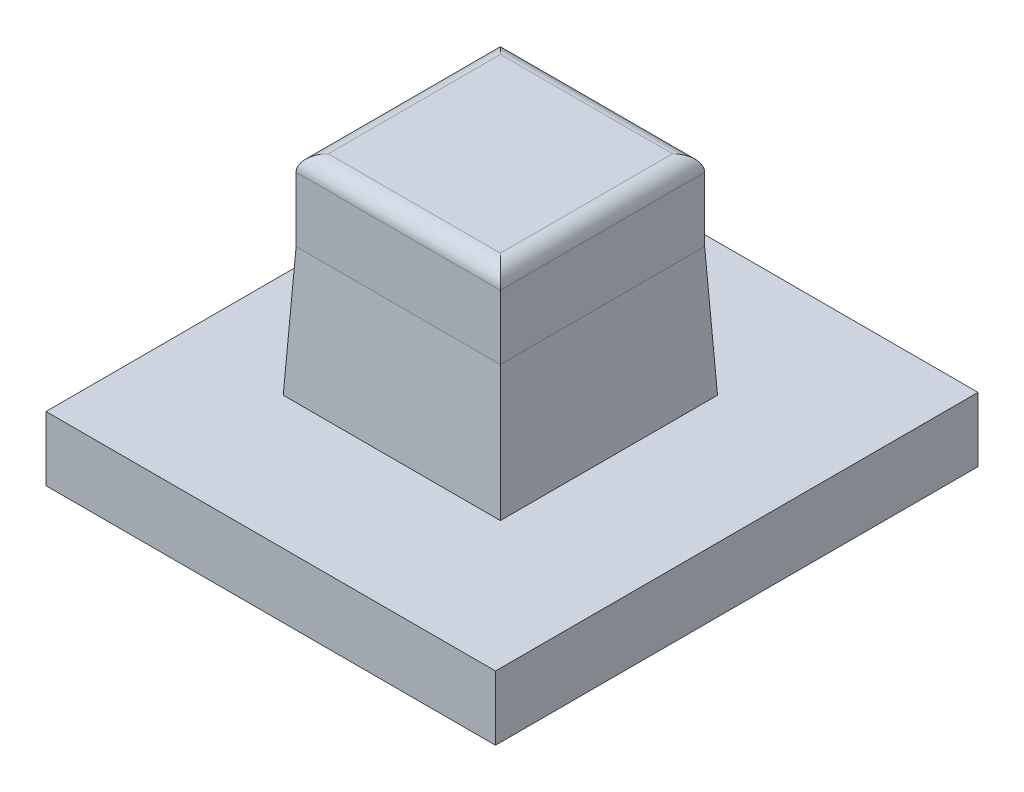
from build123d import *

# Parameters (mm, degrees)
SKETCH1_W                = 240
SKETCH1_H                = 30
SKETCH1_W_2              = 12.7
SKETCH1_H_2              = 12.7
BOSS_EXTRUDE1_DEPTH      = 4
SKETCH2_W                = 12.7
SKETCH2_H                = 12.7
BOSS_EXTRUDE2_DEPTH      = 13
BOSS_EXTRUDE2_DEPTH_BACK = 4
SKETCH3_W                = 217.126937851
SKETCH3_H                = 95.437848018
CUT_EXTRUDE1_DEPTH       = 14
CUT_EXTRUDE1_DEPTH_BACK  = 5
FILLET1_R                = 1
CHAMFER1_SIZE            = 0.4
CHAMFER1_SIZE2           = 8


with BuildPart() as part:
    # Sketch1 → Boss-Extrude1 (new body)
    with BuildSketch(Plane(origin=(0, 0, 0), x_dir=(1, 0, 0), z_dir=(0, 1, 0))):
        with Locations((120, 15)):
            Rectangle(SKETCH1_W, SKETCH1_H)
        with Locations((13.25, 15)):
            Rectangle(SKETCH1_W_2, SKETCH1_H_2, mode=Mode.SUBTRACT)
        with Locations((43.75, 15)):
            Rectangle(SKETCH1_W_2, SKETCH1_H_2, mode=Mode.SUBTRACT)
        with Locations((74.25, 15)):
            Rectangle(SKETCH1_W_2, SKETCH1_H_2, mode=Mode.SUBTRACT)
        with Locations((104.75, 15)):
            Rectangle(SKETCH1_W_2, SKETCH1_H_2, mode=Mode.SUBTRACT)
        with Locations((135.25, 15)):
            Rectangle(SKETCH1_W_2, SKETCH1_H_2, mode=Mode.SUBTRACT)
        with Locations((165.75, 15)):
            Rectangle(SKETCH1_W_2, SKETCH1_H_2, mode=Mode.SUBTRACT)
        with Locations((196.25, 15)):
            Rectangle(SKETCH1_W_2, SKETCH1_H_2, mode=Mode.SUBTRACT)
        with Locations((226.75, 15)):
            Rectangle(SKETCH1_W_2, SKETCH1_H_2, mode=Mode.SUBTRACT)
    extrude(amount=BOSS_EXTRUDE1_DEPTH)

    # Sketch2 → Boss-Extrude2 (add, two sides)
    with BuildSketch(Plane(origin=(0, 4, 0), x_dir=(1, 0, 0), z_dir=(0, 1, 0))) as boss_extrude2_sk:
        with Locations((13.25, 15)):
            Rectangle(SKETCH2_W, SKETCH2_H)
        with Locations((43.75, 15)):
            Rectangle(SKETCH2_W, SKETCH2_H)
        with Locations((74.25, 15)):
            Rectangle(SKETCH2_W, SKETCH2_H)
        with Locations((104.75, 15)):
            Rectangle(SKETCH2_W, SKETCH2_H)
        with Locations((135.25, 15)):
            Rectangle(SKETCH2_W, SKETCH2_H)
        with Locations((165.75, 15)):
            Rectangle(SKETCH2_W, SKETCH2_H)
        with Locations((196.25, 15)):
            Rectangle(SKETCH2_W, SKETCH2_H)
        with Locations((226.75, 15)):
            Rectangle(SKETCH2_W, SKETCH2_H)
    extrude(amount=BOSS_EXTRUDE2_DEPTH)
    extrude(boss_extrude2_sk.sketch, amount=-BOSS_EXTRUDE2_DEPTH_BACK)

    # Sketch3 → Cut-Extrude1 (cut, two sides)
    with BuildSketch(Plane(origin=(0, 4, 0), x_dir=(1, 0, 0), z_dir=(0, 1, 0))) as cut_extrude1_sk:
        with Locations((136.509114297, 10.683129124)):
            Rectangle(SKETCH3_W, SKETCH3_H)
    extrude(amount=CUT_EXTRUDE1_DEPTH, mode=Mode.SUBTRACT)
    extrude(cut_extrude1_sk.sketch, amount=-CUT_EXTRUDE1_DEPTH_BACK, mode=Mode.SUBTRACT)

    # Fillet1
    fillet1_edges = [part.edges().sort_by_distance(p)[0] for p in [
        (6.9, 17, -15),
        (13.25, 17, -8.65),
        (19.6, 17, -15),
        (13.25, 17, -21.35),
    ]]
    fillet(fillet1_edges, radius=FILLET1_R)

    # Chamfer1
    chamfer1_edges = [part.edges().sort_by_distance(p)[0] for p in [
        (6.9, 4, -15),
        (13.25, 4, -8.65),
        (19.6, 4, -15),
        (13.25, 4, -21.35),
    ]]
    chamfer1_side = [part.faces().sort_by_distance(p)[0] for p in [
        (0.409995012, 4, -15),
    ]]
    chamfer(chamfer1_edges, length=CHAMFER1_SIZE, length2=CHAMFER1_SIZE2, reference=chamfer1_side[0])


solid = part.part
